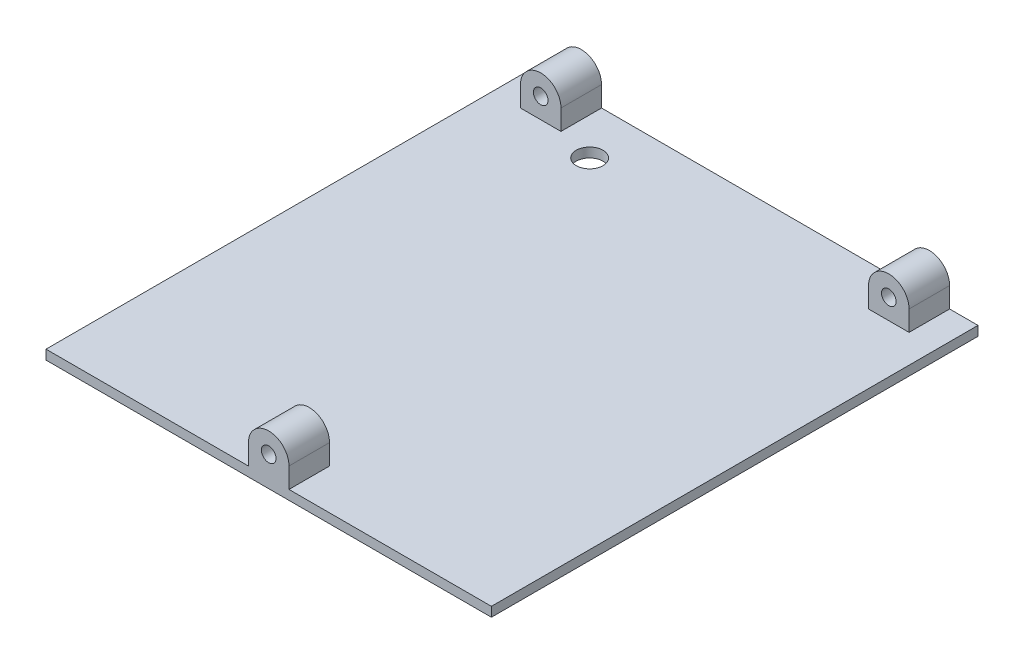
from build123d import *

# Parameters (mm, degrees)
SKETCH1_W           = 139.5
SKETCH1_H           = 152.4
BOSS_EXTRUDE1_DEPTH = 6.35
SKETCH2_W           = 139.5
SKETCH2_H           = 152.4
CUT_EXTRUDE1_DEPTH  = 3.375
SKETCH3_R           = 2.286
BOSS_EXTRUDE2_DEPTH = 12.7
SKETCH4_R           = 2.286
BOSS_EXTRUDE3_DEPTH = 12.7
SKETCH5_R           = 4.191
CUT_EXTRUDE2_DEPTH  = 16.675000158


with BuildPart() as part:
    # Sketch1 → Boss-Extrude1 (new body)
    with BuildSketch(Plane(origin=(0, 0, 0), x_dir=(1, 0, 0), z_dir=(0, 1, 0))):
        with Locations((69.75, 76.2)):
            Rectangle(SKETCH1_W, SKETCH1_H)
    extrude(amount=BOSS_EXTRUDE1_DEPTH)

    # Sketch2 → Cut-Extrude1 (cut)
    with BuildSketch(Plane(origin=(0, 6.35, 0), x_dir=(1, 0, 0), z_dir=(0, 1, 0))):
        with Locations((69.75, 76.2)):
            Rectangle(SKETCH2_W, SKETCH2_H)
    extrude(amount=-CUT_EXTRUDE1_DEPTH, mode=Mode.SUBTRACT)

    # Sketch3 → Boss-Extrude2 (add)
    with BuildSketch(Plane.XY):
        with BuildLine():
            Line((63.4, 9.325), (63.4, 2.975))
            Line((63.4, 2.975), (76.1, 2.975))
            Line((76.1, 2.975), (76.1, 9.325000158))
            ThreePointArc((76.1, 9.325000158), (69.749999921, 15.675000158), (63.4, 9.325))
        make_face()
        with Locations((69.75, 9.325000158)):
            Circle(SKETCH3_R, mode=Mode.SUBTRACT)
    extrude(amount=-BOSS_EXTRUDE2_DEPTH)

    # Sketch4 → Boss-Extrude3 (add)
    with BuildSketch(Plane(origin=(0, 0, -152.4), x_dir=(-1, 0, 0), z_dir=(0, 0, -1))):
        with BuildLine():
            Line((-130.61, 9.325), (-130.61, 2.975))
            Line((-130.61, 2.975), (-117.91, 2.975))
            Line((-117.91, 2.975), (-117.91, 9.325))
            ThreePointArc((-117.91, 9.325), (-124.26, 15.675), (-130.61, 9.325))
        make_face()
        with Locations((-124.26, 9.325)):
            Circle(SKETCH4_R, mode=Mode.SUBTRACT)
        with BuildLine():
            Line((-21.59, 9.325), (-21.59, 2.975))
            Line((-21.59, 2.975), (-8.89, 2.975))
            Line((-8.89, 2.975), (-8.89, 9.325))
            ThreePointArc((-8.89, 9.325), (-15.24, 15.675), (-21.59, 9.325))
        make_face()
        with Locations((-15.24, 9.325)):
            Circle(SKETCH4_R, mode=Mode.SUBTRACT)
    extrude(amount=-BOSS_EXTRUDE3_DEPTH)

    # Sketch5 → Cut-Extrude2 (cut, through all)
    with BuildSketch(Plane.XZ):
        with Locations((33.274, -136.991598)):
            Circle(SKETCH5_R)
    extrude(amount=-CUT_EXTRUDE2_DEPTH, mode=Mode.SUBTRACT)


solid = part.part
